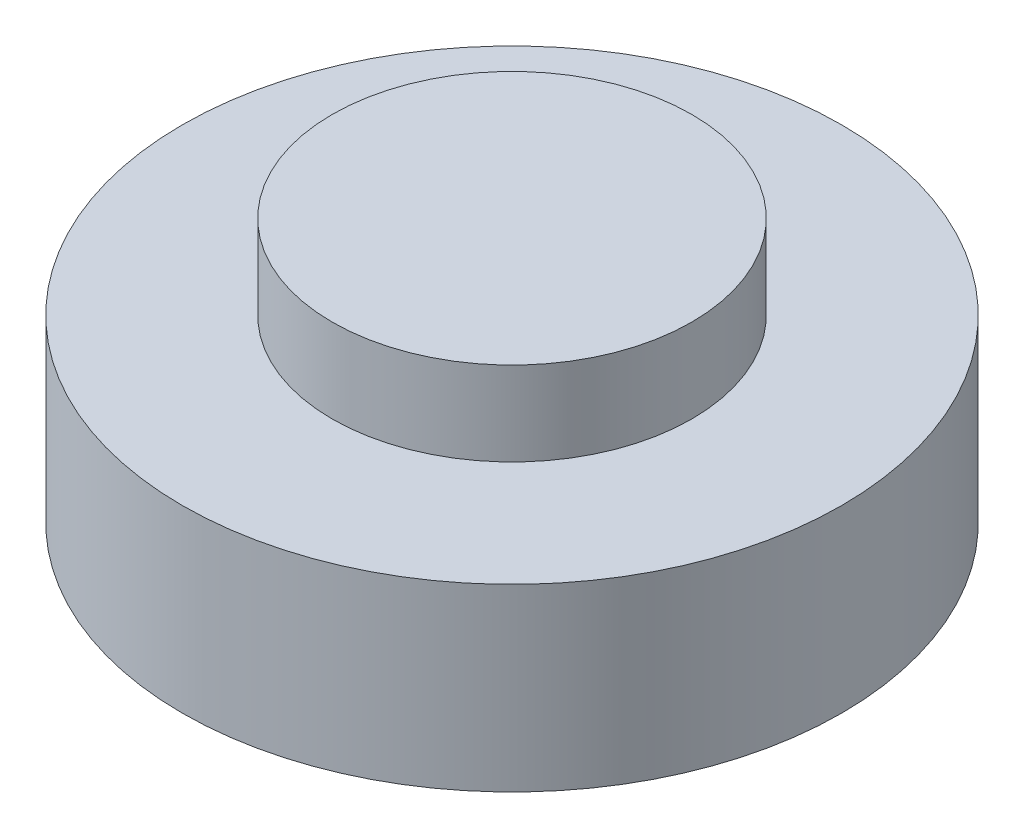
from build123d import *

# Parameters (mm, degrees)
SKETCH1_R           = 27.5
BOSS_EXTRUDE1_DEPTH = 15
SKETCH2_R           = 15
BOSS_EXTRUDE2_DEPTH = 7


with BuildPart() as part:
    # Sketch1 → Boss-Extrude1 (new body)
    with BuildSketch(Plane(origin=(0, 0, 0), x_dir=(1, 0, 0), z_dir=(0, 1, 0))):
        Circle(SKETCH1_R)
    extrude(amount=BOSS_EXTRUDE1_DEPTH)

    # Sketch2 → Boss-Extrude2 (add)
    with BuildSketch(Plane(origin=(0, 15, 0), x_dir=(1, 0, 0), z_dir=(0, 1, 0))):
        Circle(SKETCH2_R)
    extrude(amount=BOSS_EXTRUDE2_DEPTH)


solid = part.part
